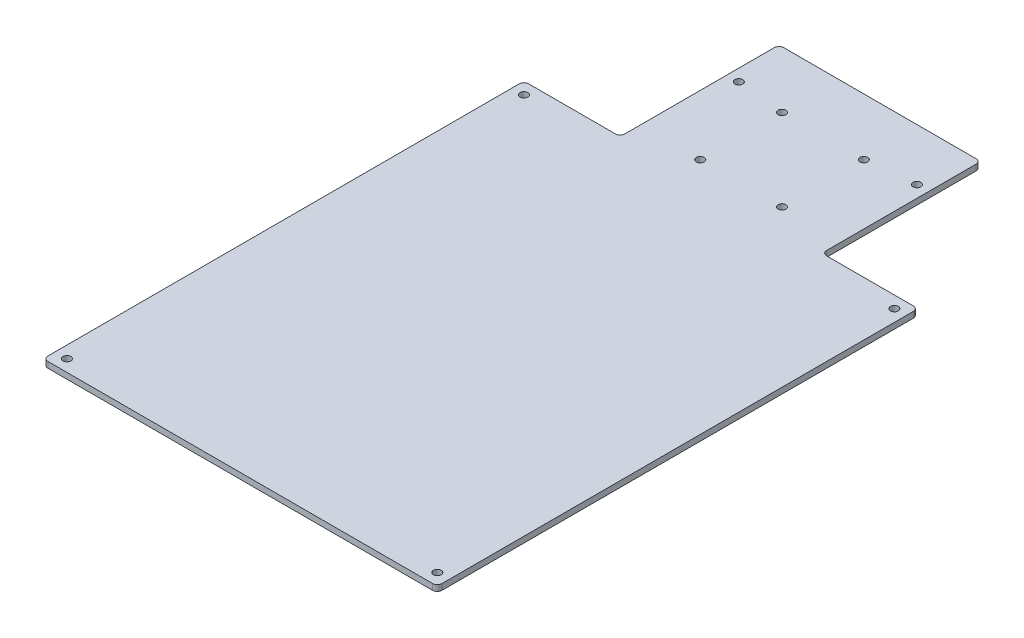
from build123d import *

# Parameters (mm, degrees)
SKETCH1_W           = 210.82
SKETCH1_H           = 257.175
SKETCH1_W_2         = 185.42
SKETCH1_H_2         = 231.775
BOSS_EXTRUDE1_DEPTH = 3.175
SKETCH3_R           = 2.0955
CUT_EXTRUDE1_DEPTH  = 3.175
SKETCH3_3_R         = 45.33
SKETCH3_3_W         = 107.95
SKETCH3_3_H         = 21.4884
BOSS_EXTRUDE2_DEPTH = 3.175
FILLET1_R           = 2.54
SKETCH4_R           = 2.0955
CUT_EXTRUDE2_DEPTH  = 3.175


with BuildPart() as part:
    # Sketch1 → Boss-Extrude1 (new body)
    with BuildSketch(Plane(origin=(0, 0, 0), x_dir=(1, 0, 0), z_dir=(0, 1, 0))):
        with Locations((92.71, 115.8875)):
            Rectangle(SKETCH1_W, SKETCH1_H)
        with Locations((92.71, 115.8875)):
            Rectangle(SKETCH1_W_2, SKETCH1_H_2, mode=Mode.SUBTRACT)
        with Locations((92.71, 115.8875)):
            Rectangle(SKETCH1_W_2, SKETCH1_H_2)
    extrude(amount=BOSS_EXTRUDE1_DEPTH)

    # Sketch3 → Cut-Extrude1 (cut)
    with BuildSketch(Plane(origin=(0, 3.175, 0), x_dir=(1, 0, 0), z_dir=(0, 1, 0))):
        with Locations(Location((191.77, 238.125, 0), (0, 0, 270))):
            Circle(SKETCH3_R)
        with Locations(Location((191.77, -6.35, 0), (0, 0, 270))):
            Circle(SKETCH3_R)
        with Locations(Location((-6.35, -6.35, 0), (0, 0, 270))):
            Circle(SKETCH3_R)
        with Locations(Location((-6.35, 238.125, 0), (0, 0, 270))):
            Circle(SKETCH3_R)
    extrude(amount=-CUT_EXTRUDE1_DEPTH, mode=Mode.SUBTRACT)

    # Sketch3_3 → Boss-Extrude2 (add)
    with BuildSketch(Plane(origin=(0, 3.175, 0), x_dir=(1, 0, 0), z_dir=(0, 1, 0))):
        with BuildLine():
            ThreePointArc((138.04, 277.105), (134.430200877, 259.378360759), (124.175727387, 244.475))
            Line((124.175727387, 244.475), (146.685, 244.475))
            Line((146.685, 244.475), (146.685, 301.625))
            Line((146.685, 301.625), (142.4305, 301.625))
            ThreePointArc((142.4305, 301.625), (138.85325774, 300.14325774), (140.335, 303.7205))
            Line((140.335, 303.7205), (140.335, 307.975))
            Line((140.335, 307.975), (125.904156112, 307.975))
            ThreePointArc((125.904156112, 307.975), (134.897083311, 293.68989981), (138.04, 277.105))
        make_face()
        with BuildLine():
            Line((142.4305, 301.625), (146.685, 301.625))
            Line((146.685, 301.625), (146.685, 307.975))
            Line((146.685, 307.975), (140.335, 307.975))
            Line((140.335, 307.975), (140.335, 303.7205))
            ThreePointArc((140.335, 303.7205), (141.81674226, 303.10674226), (142.4305, 301.625))
        make_face()
        with BuildLine():
            Line((38.735, 244.475), (61.244272613, 244.475))
            ThreePointArc((61.244272613, 244.475), (47.396783015, 275.871603687), (59.515843888, 307.975))
            Line((59.515843888, 307.975), (45.085, 307.975))
            Line((45.085, 307.975), (45.085, 303.7205))
            ThreePointArc((45.085, 303.7205), (46.56674226, 303.10674226), (47.1805, 301.625))
            ThreePointArc((47.1805, 301.625), (45.085, 299.5295), (42.9895, 301.625))
            Line((42.9895, 301.625), (38.735, 301.625))
            Line((38.735, 301.625), (38.735, 244.475))
        make_face()
        with BuildLine():
            Line((38.735, 307.975), (38.735, 301.625))
            Line((38.735, 301.625), (42.9895, 301.625))
            ThreePointArc((42.9895, 301.625), (43.60325774, 303.10674226), (45.085, 303.7205))
            Line((45.085, 303.7205), (45.085, 307.975))
            Line((45.085, 307.975), (38.735, 307.975))
        make_face()
        with BuildLine():
            ThreePointArc((61.244272613, 244.475), (75.743989862, 235.069736233), (92.71, 231.775))
            Line((92.71, 231.775), (92.71, 244.475))
            Line((92.71, 244.475), (61.244272613, 244.475))
        make_face()
        with BuildLine():
            Line((92.71, 244.475), (92.71, 231.775))
            ThreePointArc((92.71, 231.775), (109.676010138, 235.069736233), (124.175727387, 244.475))
            Line((124.175727387, 244.475), (92.71, 244.475))
        make_face()
        with Locations((92.71, 277.105)):
            Circle(SKETCH3_3_R)
        with Locations((92.71, 318.7192)):
            Rectangle(SKETCH3_3_W, SKETCH3_3_H)
        with BuildLine():
            Line((59.515843888, 307.975), (92.71, 307.975))
            Line((92.71, 307.975), (92.71, 322.435))
            ThreePointArc((92.71, 322.435), (74.606522434, 318.663067809), (59.515843888, 307.975))
        make_face()
        with BuildLine():
            Line((92.71, 322.435), (92.71, 307.975))
            Line((92.71, 307.975), (125.904156112, 307.975))
            ThreePointArc((125.904156112, 307.975), (110.813477566, 318.663067809), (92.71, 322.435))
        make_face()
    extrude(amount=-BOSS_EXTRUDE2_DEPTH)

    # Fillet1
    fillet1_edges = [part.edges().sort_by_distance(p)[0] for p in [
        (146.685, 1.5875, -244.475),
        (38.735, 1.5875, -244.475),
        (38.735, 1.5875, -329.4634),
        (146.685, 1.5875, -329.4634),
        (-12.7, 1.5875, -244.475),
        (198.12, 1.5875, -244.475),
        (198.12, 1.5875, 12.7),
        (-12.7, 1.5875, 12.7),
    ]]
    fillet(fillet1_edges, radius=FILLET1_R)

    # Sketch4 → Cut-Extrude2 (cut)
    with BuildSketch(Plane(origin=(0, 3.175, 0), x_dir=(1, 0, 0), z_dir=(0, 1, 0))):
        with Locations(Location((70.834096089, 298.980903911, 0), (0, 0, 270))):
            Circle(SKETCH4_R)
        with Locations(Location((114.585903911, 298.980903911, 0), (0, 0, 270))):
            Circle(SKETCH4_R)
        with Locations(Location((114.585903911, 255.229096089, 0), (0, 0, 270))):
            Circle(SKETCH4_R)
        with Locations(Location((70.834096089, 255.229096089, 0), (0, 0, 270))):
            Circle(SKETCH4_R)
    extrude(amount=-CUT_EXTRUDE2_DEPTH, mode=Mode.SUBTRACT)


solid = part.part
